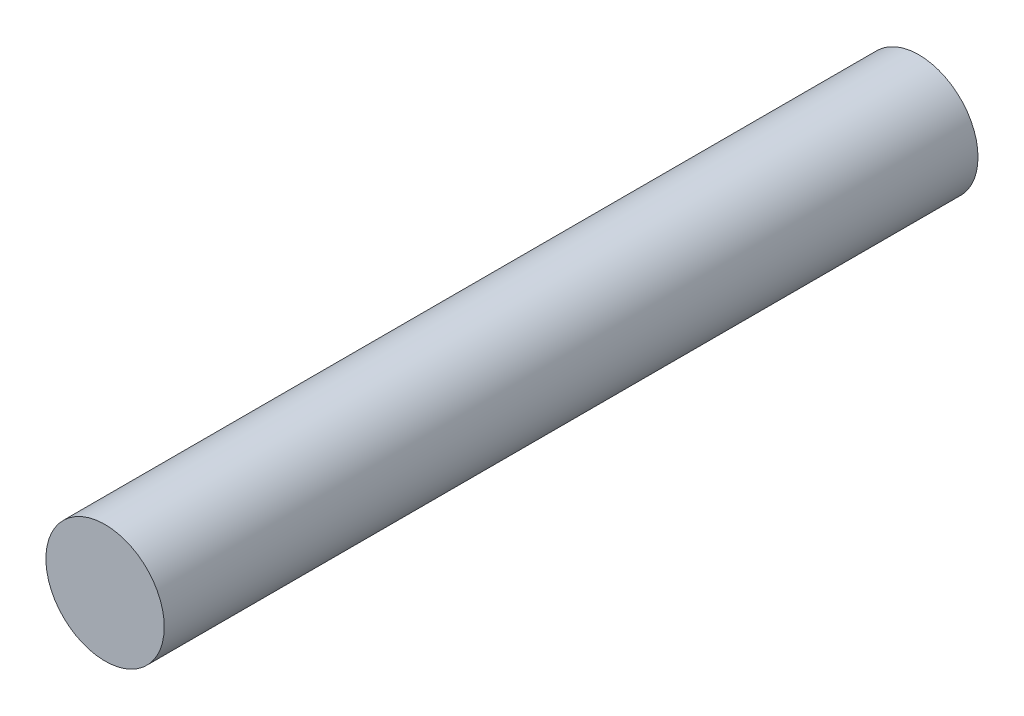
from build123d import *

# Parameters (mm, degrees)
SKETCH1_R           = 2
BOSS_EXTRUDE1_DEPTH = 27.5


with BuildPart() as part:
    # Sketch1 → Boss-Extrude1 (new body)
    with BuildSketch(Plane.XY):
        Circle(SKETCH1_R)
    extrude(amount=BOSS_EXTRUDE1_DEPTH)


solid = part.part
